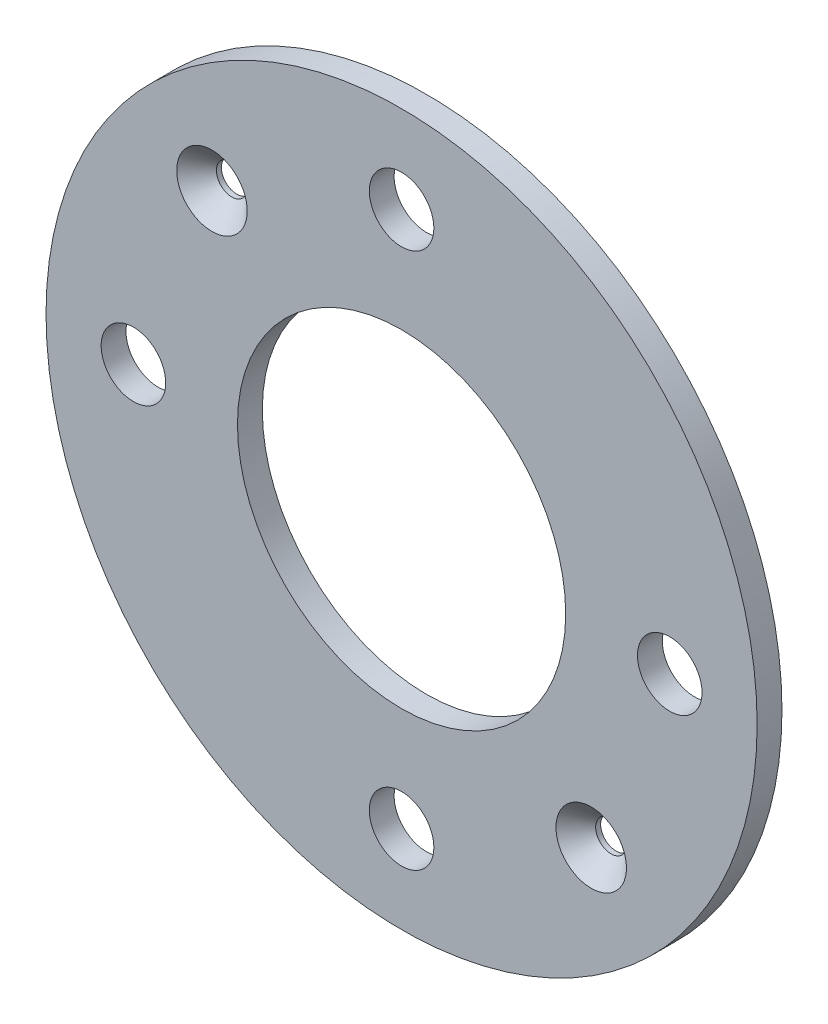
from build123d import *

# Parameters (mm, degrees)
ESQUISSE1_R             = 71.6
ESQUISSE1_R_2           = 33.05
BOSS_EXTRU_1_DEPTH      = 5
ESQUISSE2_R             = 6.5
ENL_V_MAT_EXTRU_1_DEPTH = 6
ESQUISSE3_R             = 3.1
ENL_V_MAT_EXTRU_2_DEPTH = 6
CHANFREIN1_SIZE         = 4


with BuildPart() as part:
    # Esquisse1 → Boss.-Extru.1 (new body)
    with BuildSketch(Plane.XY):
        Circle(ESQUISSE1_R)
        Circle(ESQUISSE1_R_2, mode=Mode.SUBTRACT)
    extrude(amount=BOSS_EXTRU_1_DEPTH)

    # Esquisse2 → Enlèv. mat.-Extru.1 (cut, through all)
    with BuildSketch(Plane.XY.offset(5)):
        with Locations((0, 54)):
            Circle(ESQUISSE2_R)
        with Locations((54, 0)):
            Circle(ESQUISSE2_R)
        with Locations((-54, 0)):
            Circle(ESQUISSE2_R)
        with Locations((0, -54)):
            Circle(ESQUISSE2_R)
    extrude(amount=-ENL_V_MAT_EXTRU_1_DEPTH, mode=Mode.SUBTRACT)

    # Esquisse3 → Enlèv. mat.-Extru.2 (cut, through all)
    with BuildSketch(Plane.XY.offset(5)):
        with Locations((-38.183766184, 38.183766184)):
            Circle(ESQUISSE3_R)
        with Locations((38.183766184, -38.183766184)):
            Circle(ESQUISSE3_R)
    extrude(amount=-ENL_V_MAT_EXTRU_2_DEPTH, mode=Mode.SUBTRACT)

    # Chanfrein1
    chanfrein1_edges = [part.edges().sort_by_distance(p)[0] for p in [
        (-41.283766184, 38.183766184, 5),
        (35.083766184, -38.183766184, 5),
    ]]
    chamfer(chanfrein1_edges, length=CHANFREIN1_SIZE)


solid = part.part
